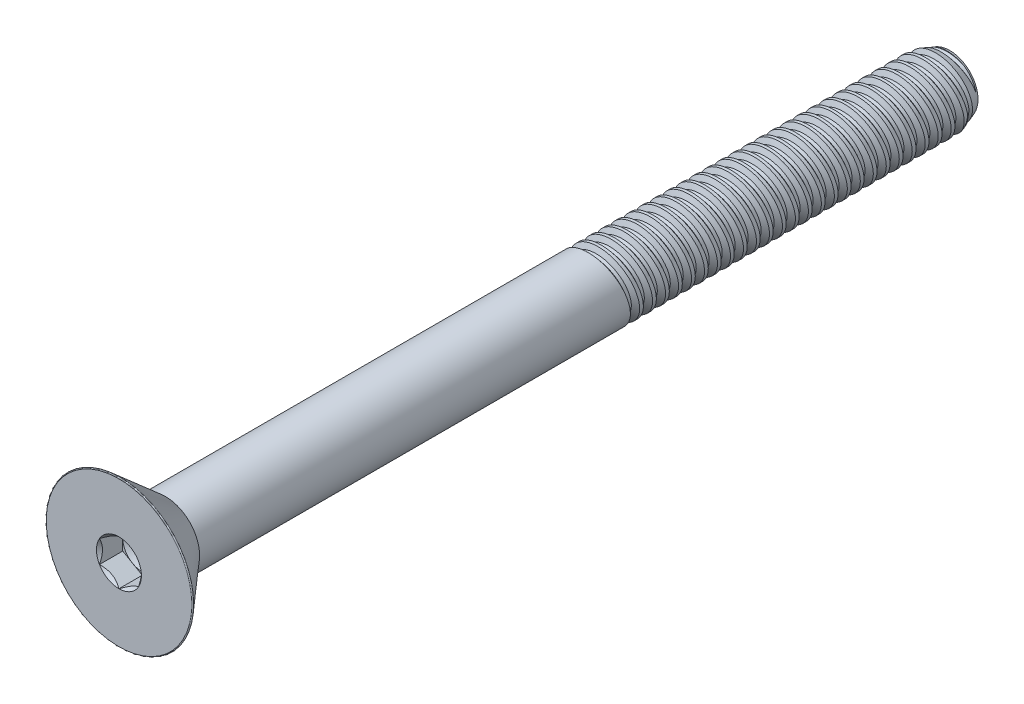
from build123d import *

# Parameters (mm, degrees)
SKETCH1_W          = 47.9552
SKETCH1_H          = 2.0828
LPATTERN1_COUNT    = 28
LPATTERN1_PITCH    = 0.79375
SKETCH4_R          = 4.5593
EXTRUDE1_DEPTH     = 2.8448
FILLET1_R          = 0.0508
CUT_EXTRUDE1_DEPTH = 1.4224
SKETCH8_R          = 1.190625
CUT_EXTRUDE5_DEPTH = 0.474133333
CUT_EXTRUDE5_DRAFT = -60


with BuildPart() as part:
    # Sketch1 → Revolve1 (revolve)
    with BuildSketch(Plane(origin=(0, 0, 0), x_dir=(0, 0, -1), z_dir=(1, 0, 0))):
        with Locations((23.9776, 1.0414)):
            Rectangle(SKETCH1_W, SKETCH1_H)
    revolve(axis=Axis((0, 0, 0), (0, 0, 1)))

    # Sketch2 → Cut-Revolve1 (revolve, cut)
    with BuildSketch(Plane(origin=(0, 0, 0), x_dir=(0, 0, -1), z_dir=(1, 0, 0)), mode=Mode.PRIVATE) as cut_revolve1_sk:
        Polygon((25.827665104, 2.101371857), (26.509920832, 2.231374854), (26.34667657, 1.762908932), (26.151746362, 1.725765218), align=None)
    cut_revolve1 = revolve(cut_revolve1_sk.sketch.rotate(Axis((0, -0.162231854, -25.7302), (0, 0.187180917921561, -0.9823254572523518)), 180), axis=Axis((0, -0.162231854, -25.7302), (0, 0.187180917921561, -0.9823254572523518)), mode=Mode.SUBTRACT)

    # Sketch3 → Cut-Revolve2 (revolve, cut)
    with BuildSketch(Plane(origin=(0, 0, 0), x_dir=(0, 0, -1), z_dir=(1, 0, 0))):
        Polygon((47.9552, 1.725765218), (46.974255, 2.0828), (47.9552, 2.0828), align=None)
    revolve(axis=Axis((0, 0, -46.974255), (0, 0, 1)), mode=Mode.SUBTRACT)

    # LPattern1: Cut-Revolve1 ×28
    with Locations(*[(0, 0, -i * LPATTERN1_PITCH) for i in range(1, LPATTERN1_COUNT)]):
        add(cut_revolve1, mode=Mode.SUBTRACT)

    # Sketch4 → Extrude1 (add)
    with BuildSketch(Plane.XY):
        Circle(SKETCH4_R)
    extrude(amount=EXTRUDE1_DEPTH)

    # Sketch9 → Cut-Revolve3 (revolve, cut)
    with BuildSketch(Plane(origin=(0, 0, 0), x_dir=(0, 0, -1), z_dir=(1, 0, 0)), mode=Mode.PRIVATE) as cut_revolve3_sk:
        Polygon((-2.8448, 4.5593), (0, 2.086353088), (0, 4.5593), align=None)
    revolve(cut_revolve3_sk.sketch.rotate(Axis((0, 0, 0), (0, 0, 1)), 143.466023127), axis=Axis((0, 0, 0), (0, 0, 1)), mode=Mode.SUBTRACT)

    # Fillet1
    fillet1_edges = [part.edges().sort_by_distance(p)[0] for p in [
        (2.714148445, 3.663415716, 2.8448),
    ]]
    fillet(fillet1_edges, radius=FILLET1_R)

    # Sketch6 → Cut-Extrude1 (cut)
    with BuildSketch(Plane.XY.offset(2.8448)):
        Polygon((0, -1.374815329), (1.190625, -0.687407664), (1.190625, 0.687407664), (0, 1.374815329), (-1.190625, 0.687407664), (-1.190625, -0.687407664), align=None)
    extrude(amount=-CUT_EXTRUDE1_DEPTH, mode=Mode.SUBTRACT)

    # Cut-Extrude4 cone 1 section (through the dimple's axis) → Cut-Extrude4 (revolve, cut)
    with BuildSketch(Plane(origin=(0, 0, 2.8448), x_dir=(0, -1, 0), z_dir=(1, 0, 0))):
        Polygon((0, 0), (1.374815329, 0), (0, 1.374815329), align=None)
    revolve(axis=Axis((0, 0, 2.8448), (0, 0, -1)), mode=Mode.SUBTRACT)


with BuildPart() as cut_extrude5_tool:
    # Sketch8 → Cut-Extrude5 (with draft: the straight prism first)
    with BuildSketch(Plane.XY.offset(1.4224)):
        Circle(SKETCH8_R)
    extrude(amount=-CUT_EXTRUDE5_DEPTH)
    # Cut-Extrude5: the draft: its side faces are tilted about the plane it starts from
    cut_extrude5_sides = [cut_extrude5_tool.faces().sort_by_distance(p)[0] for p in [
        (-1.190625, 0, 1.185333333),
    ]]
    draft(cut_extrude5_sides, Plane.XY.offset(1.4224), CUT_EXTRUDE5_DRAFT)


with BuildPart() as part_1:
    add(part.part)

    # Cut-Extrude5: cut by cut_extrude5_tool
    add(cut_extrude5_tool.part, mode=Mode.SUBTRACT)


solid = part_1.part
